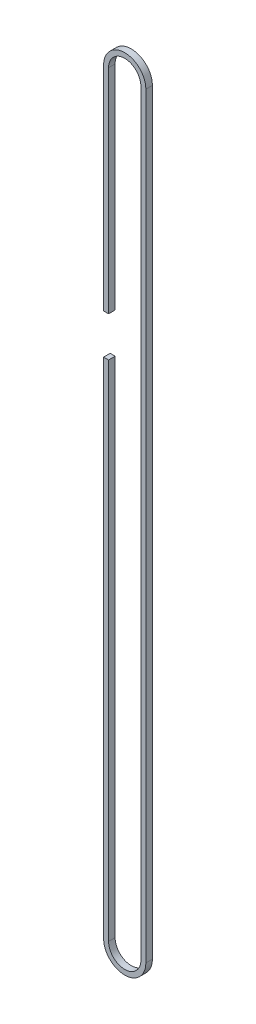
from build123d import *

# Parameters (mm, degrees)
BOSS_EXTRUDE1_DEPTH = 3.8989


with BuildPart() as part:
    # Sketch1 → Boss-Extrude1 (new body, symmetric)
    with BuildSketch(Plane.XY):
        with BuildLine():
            Line((-25.1587, 901.7), (-25.1587, 647.7))
            Line((-25.1587, 647.7), (-19.2659, 647.7))
            Line((-19.2659, 647.7), (-19.2659, 901.7))
            ThreePointArc((-19.2659, 901.7), (0, 920.9659), (19.2659, 901.7))
            Line((19.2659, 901.7), (19.2659, 0))
            ThreePointArc((19.2659, 0), (0, -19.2659), (-19.2659, 0))
            Line((-19.2659, 0), (-19.2659, 600.075))
            Line((-19.2659, 600.075), (-25.1587, 600.075))
            Line((-25.1587, 600.075), (-25.1587, 0))
            ThreePointArc((-25.1587, 0), (0, -25.1587), (25.1587, 0))
            Line((25.1587, 0), (25.1587, 901.7))
            ThreePointArc((25.1587, 901.7), (0, 926.8587), (-25.1587, 901.7))
        make_face()
    extrude(amount=BOSS_EXTRUDE1_DEPTH, both=True)


solid = part.part
